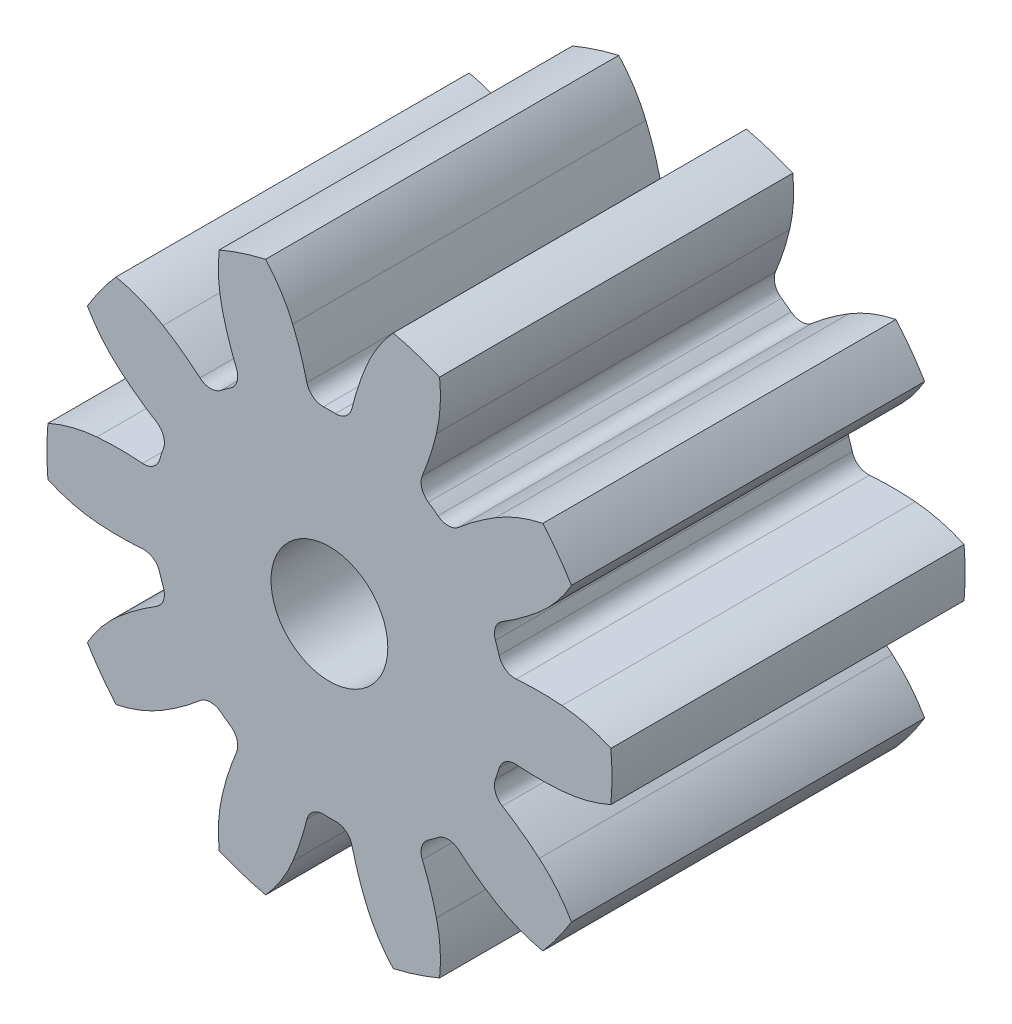
from build123d import *

# Parameters (mm, degrees)
SKETCH1_R           = 7.62
ROUND_STOCK_DEPTH   = 4.7625
SINGLE_TOOTH_DEPTH  = 15.382434599
TOOTH_PATTERN_COUNT = 10
SKETCH5_R           = 1.5748
CUT_EXTRUDE1_DEPTH  = 15.279088802


with BuildPart() as part:
    # Sketch1 → Round Stock (new, symmetric)
    with BuildSketch(Plane.XY):
        Circle(SKETCH1_R)
    extrude(amount=ROUND_STOCK_DEPTH, both=True)

    # Sketch2 → Single Tooth (cut, through all)
    with BuildSketch(Plane.XY.offset(4.7625)):
        with BuildLine():
            ThreePointArc((-6.527946851, -3.930688223), (-7.247050654, -2.354709497), (-7.59162051, -0.657037315))
            ThreePointArc((-7.59162051, -0.657037315), (-6.946040634, -0.884136963), (-6.271150147, -0.997585))
            ThreePointArc((-6.271150147, -0.997585), (-5.655082128, -1.02259203), (-5.038991647, -0.998144603))
            ThreePointArc((-5.038991647, -0.998144603), (-4.750649746, -1.075701008), (-4.576435033, -1.318199012))
            ThreePointArc((-4.576435033, -1.318199012), (-4.529406659, -1.471693436), (-4.477231654, -1.623515618))
            ThreePointArc((-4.477231654, -1.623515618), (-4.475637567, -1.922101463), (-4.663324555, -2.15432903))
            ThreePointArc((-4.663324555, -2.15432903), (-5.17612206, -2.496679544), (-5.659832794, -2.879026353))
            ThreePointArc((-5.659832794, -2.879026353), (-6.139147584, -3.367498418), (-6.527946851, -3.930688223))
        make_face()
    single_tooth = extrude(amount=-SINGLE_TOOTH_DEPTH, mode=Mode.SUBTRACT)

    # Tooth Pattern: Single Tooth ×10 about axis
    tooth_pattern_axis = Axis((0, 0, 50), (0, 0, -1))
    for i in range(1, TOOTH_PATTERN_COUNT):
        add(single_tooth.rotate(tooth_pattern_axis, i * 360 / TOOTH_PATTERN_COUNT), mode=Mode.SUBTRACT)

    # Sketch5 → Cut-Extrude1 (cut, through all)
    with BuildSketch(Plane.XY.offset(4.7625)):
        Circle(SKETCH5_R)
    extrude(amount=-CUT_EXTRUDE1_DEPTH, mode=Mode.SUBTRACT)


solid = part.part
